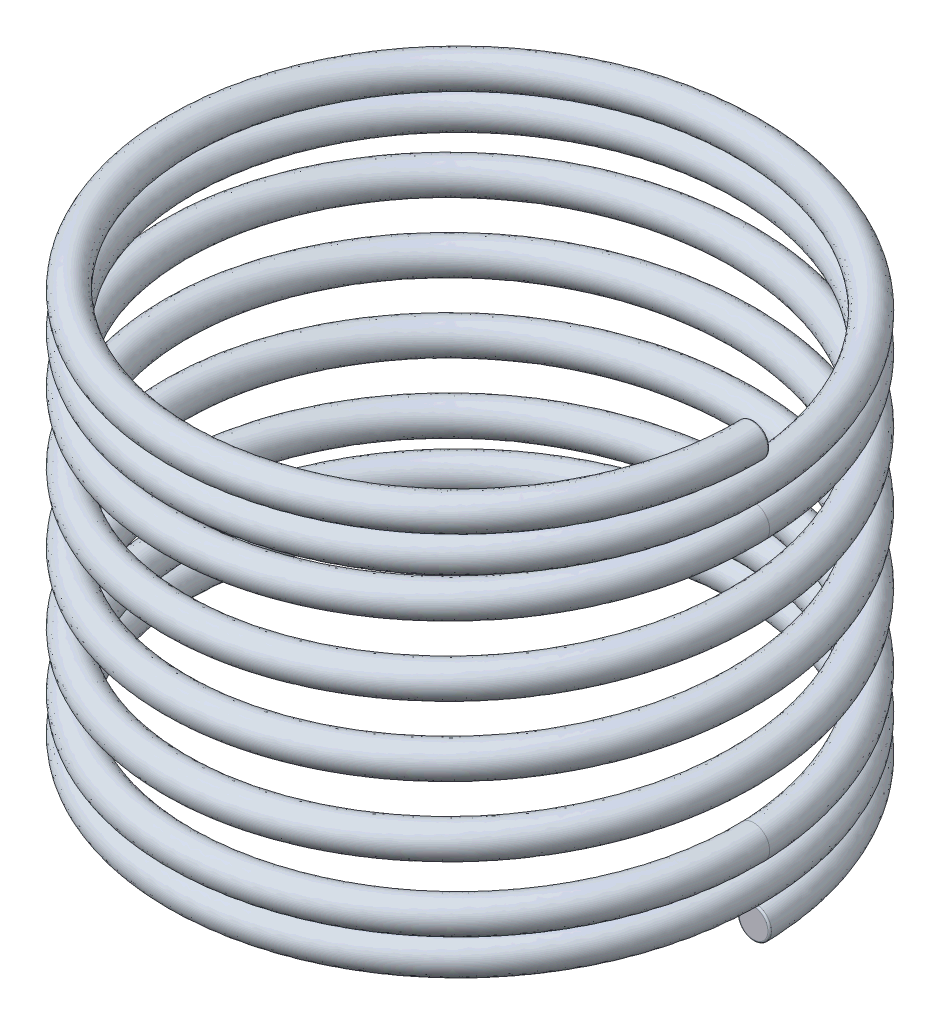
from build123d import *

# Parameters (mm, degrees)
SWEEP1_PITCH       = 0.5
SWEEP1_HEIGHT      = 1
SWEEP1_RADIUS      = 4
SWEEP1_START_ANGLE = 90
SKETCH14_R         = 0.2275
SWEEP2_PITCH       = 0.98015
SWEEP2_HEIGHT      = 3.9206
SWEEP2_RADIUS      = 4
SWEEP2_START_ANGLE = 90
SKETCH16_R         = 0.2275
SWEEP3_PITCH       = 0.5
SWEEP3_HEIGHT      = 1
SWEEP3_RADIUS      = 4
SWEEP3_START_ANGLE = 90
SKETCH17_R         = 0.2275
FILLET2_R          = 0.025
FILLET3_R          = 0.025


with BuildPart() as part:
    # Sweep1: sweep along a helix
    with BuildLine() as sweep1_path:
        add(Helix(SWEEP1_PITCH, SWEEP1_HEIGHT, SWEEP1_RADIUS, center=(0, 0, 0), direction=(0, -1, 0), mode=Mode.PRIVATE).rotate(Axis((0, 0, 0), (0, -1, 0)), SWEEP1_START_ANGLE))
    # Sketch14 → Sweep1 (sweep)
    with BuildSketch(Plane.XY):
        with Locations((4, 0)):
            Circle(SKETCH14_R)
    sweep(path=sweep1_path.line, is_frenet=True)

    # Sweep2: sweep along a helix
    with BuildLine() as sweep2_path:
        add(Helix(SWEEP2_PITCH, SWEEP2_HEIGHT, SWEEP2_RADIUS, center=(0, -1, 0), direction=(0, -1, 0), mode=Mode.PRIVATE).rotate(Axis((0, -1, 0), (0, -1, 0)), SWEEP2_START_ANGLE))
    # Sketch16 → Sweep2 (sweep)
    with BuildSketch(Plane.XY):
        with Locations((4, -1)):
            Circle(SKETCH16_R)
    sweep(path=sweep2_path.line, is_frenet=True)

    # Sweep3: sweep along a helix
    with BuildLine() as sweep3_path:
        add(Helix(SWEEP3_PITCH, SWEEP3_HEIGHT, SWEEP3_RADIUS, center=(0, -4.9206, 0), direction=(0, -1, 0), mode=Mode.PRIVATE).rotate(Axis((0, -4.9206, 0), (0, -1, 0)), SWEEP3_START_ANGLE))
    # Sketch17 → Sweep3 (sweep)
    with BuildSketch(Plane.XY):
        with Locations((4, -4.9206)):
            Circle(SKETCH17_R)
    sweep(path=sweep3_path.line, is_frenet=True)

    # Fillet2
    fillet2_edges = [part.edges().sort_by_distance(p)[0] for p in [
        (3.7725, -5.9206, 0),
    ]]
    fillet(fillet2_edges, radius=FILLET2_R)

    # Fillet3
    fillet3_edges = [part.edges().sort_by_distance(p)[0] for p in [
        (3.7725, 0, 0),
    ]]
    fillet(fillet3_edges, radius=FILLET3_R)


solid = part.part
